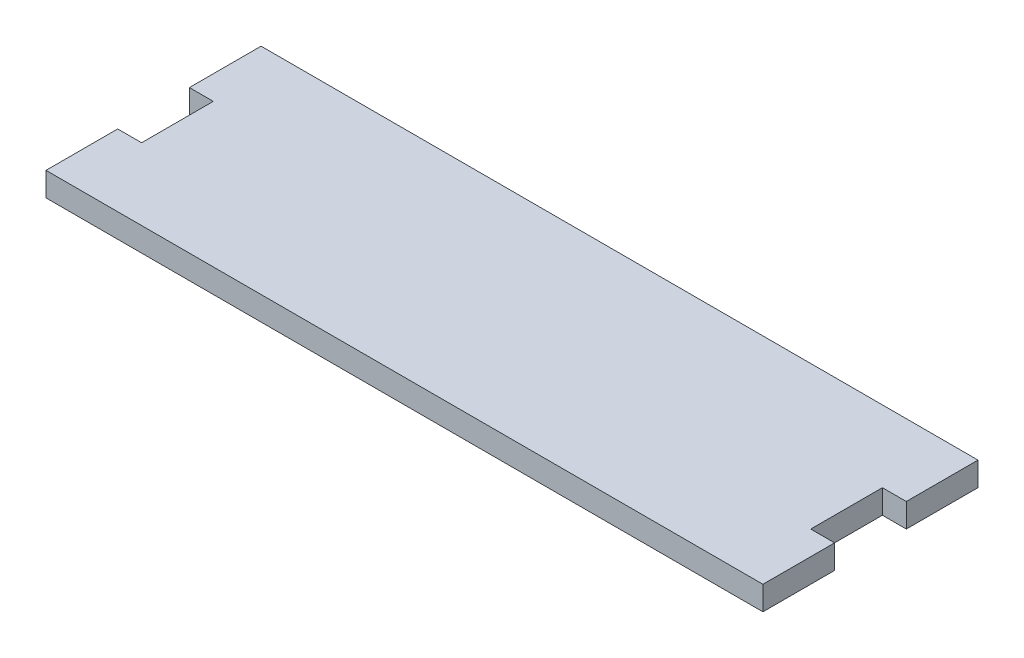
from build123d import *

# Parameters (mm, degrees)
SKETCH_1_W      = 140
SKETCH_1_H      = 45
SKETCH_1_W_2    = 5
SKETCH_1_H_2    = 15
EXTRUDE_1_DEPTH = 5


with BuildPart() as part:
    # 草图1 → 凸台-拉伸1 (new body)
    with BuildSketch(Plane(origin=(0, 0, 0), x_dir=(1, 0, 0), z_dir=(0, 1, 0))):
        Rectangle(SKETCH_1_W, SKETCH_1_H)
        with Locations((-72.5, 15)):
            Rectangle(SKETCH_1_W_2, SKETCH_1_H_2)
        with Locations((-72.5, -15)):
            Rectangle(SKETCH_1_W_2, SKETCH_1_H_2)
        with Locations((72.5, 15)):
            Rectangle(SKETCH_1_W_2, SKETCH_1_H_2)
        with Locations((72.5, -15)):
            Rectangle(SKETCH_1_W_2, SKETCH_1_H_2)
    extrude(amount=EXTRUDE_1_DEPTH)


solid = part.part
